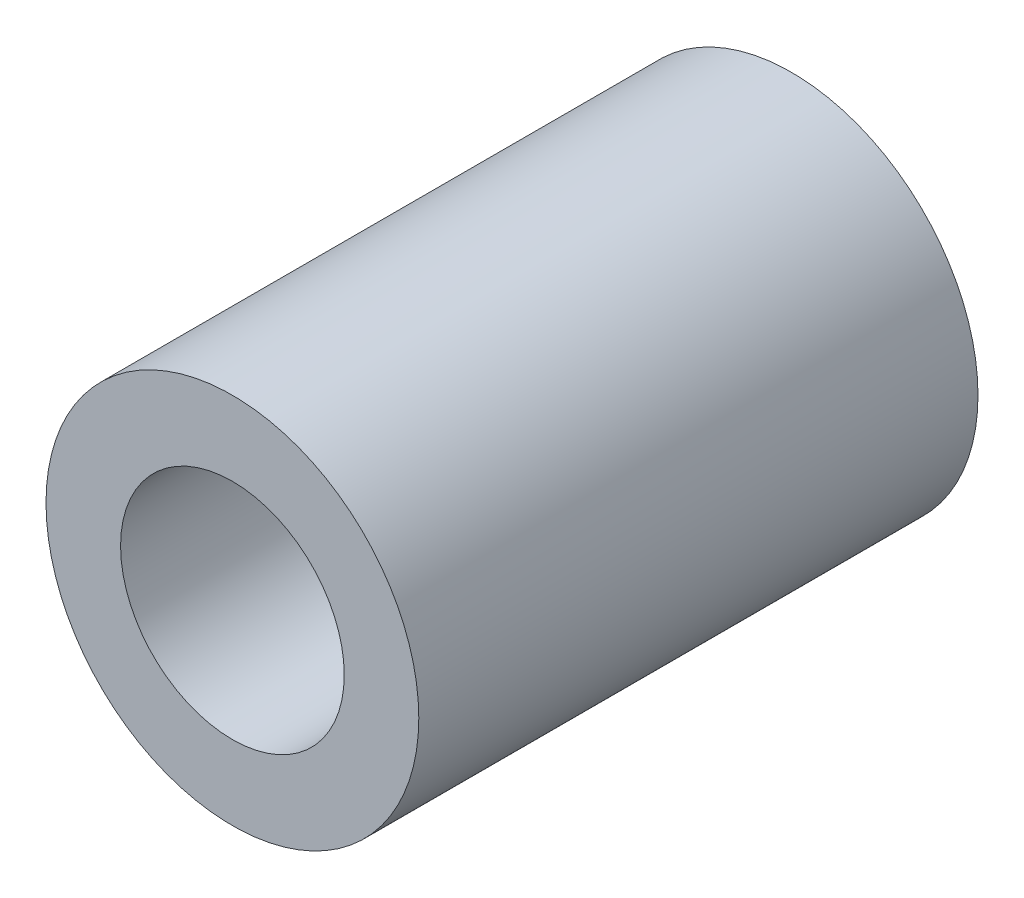
from build123d import *

# Parameters (mm, degrees)
SKETCH2_R           = 2.5
SKETCH2_R_2         = 1.5
BOSS_EXTRUDE1_DEPTH = 7.5


with BuildPart() as part:
    # Sketch2 → Boss-Extrude1 (new body)
    with BuildSketch(Plane.XY):
        Circle(SKETCH2_R)
        Circle(SKETCH2_R_2, mode=Mode.SUBTRACT)
    extrude(amount=BOSS_EXTRUDE1_DEPTH)


solid = part.part
